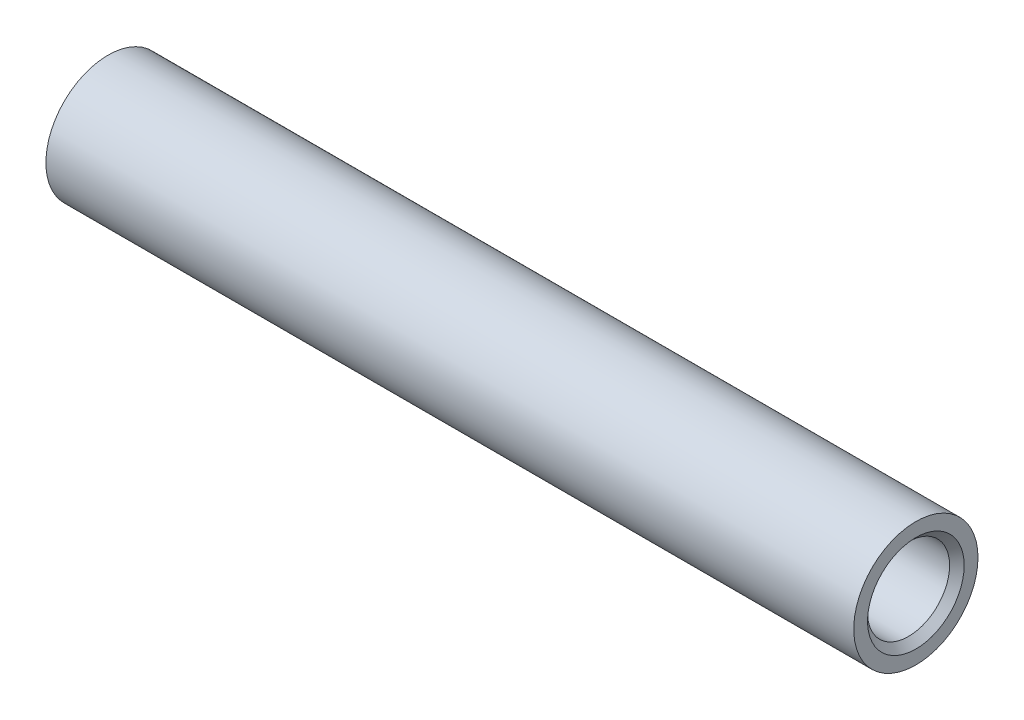
from build123d import *

# Parameters (mm, degrees)
SKETCH_1_R                      = 5
EXTRUDE_2_DEPTH                 = 65
HOLE_WIZARD_G1_16_1_D           = 6.6
HOLE_WIZARD_G1_16_1_DEPTH       = 20
HOLE_WIZARD_G1_16_1_CSINK_D     = 7.773
HOLE_WIZARD_G1_16_1_CSINK_ANGLE = 90
HOLE_WIZARD_G1_16_1_TIP         = 1.982840043
HOLE_WIZARD_G1_16_2_D           = 6.6
HOLE_WIZARD_G1_16_2_DEPTH       = 20
HOLE_WIZARD_G1_16_2_CSINK_D     = 7.773
HOLE_WIZARD_G1_16_2_CSINK_ANGLE = 90
HOLE_WIZARD_G1_16_2_TIP         = 1.982840043


with BuildPart() as part:
    # 草图1 → 凸台-拉伸2 (new body)
    with BuildSketch(Plane(origin=(0, 0, 0), x_dir=(0, 0, -1), z_dir=(1, 0, 0))):
        Circle(SKETCH_1_R)
    extrude(amount=EXTRUDE_2_DEPTH)

    # G1/16 螺纹孔1
    with Locations(Plane.ZY):
        with Locations((0, 0)):
            CounterSinkHole(HOLE_WIZARD_G1_16_1_D / 2, HOLE_WIZARD_G1_16_1_CSINK_D / 2, depth=HOLE_WIZARD_G1_16_1_DEPTH, counter_sink_angle=HOLE_WIZARD_G1_16_1_CSINK_ANGLE)
            with Locations((0, 0, -(HOLE_WIZARD_G1_16_1_DEPTH + HOLE_WIZARD_G1_16_1_TIP / 2))):  # 118° drill point
                Cone(0, HOLE_WIZARD_G1_16_1_D / 2, HOLE_WIZARD_G1_16_1_TIP, mode=Mode.SUBTRACT)

    # G1/16 螺纹孔2
    with Locations(Plane(origin=(65, 0, 0), x_dir=(0, 0, -1), z_dir=(1, 0, 0))):
        with Locations((0, 0)):
            CounterSinkHole(HOLE_WIZARD_G1_16_2_D / 2, HOLE_WIZARD_G1_16_2_CSINK_D / 2, depth=HOLE_WIZARD_G1_16_2_DEPTH, counter_sink_angle=HOLE_WIZARD_G1_16_2_CSINK_ANGLE)
            with Locations((0, 0, -(HOLE_WIZARD_G1_16_2_DEPTH + HOLE_WIZARD_G1_16_2_TIP / 2))):  # 118° drill point
                Cone(0, HOLE_WIZARD_G1_16_2_D / 2, HOLE_WIZARD_G1_16_2_TIP, mode=Mode.SUBTRACT)


solid = part.part
